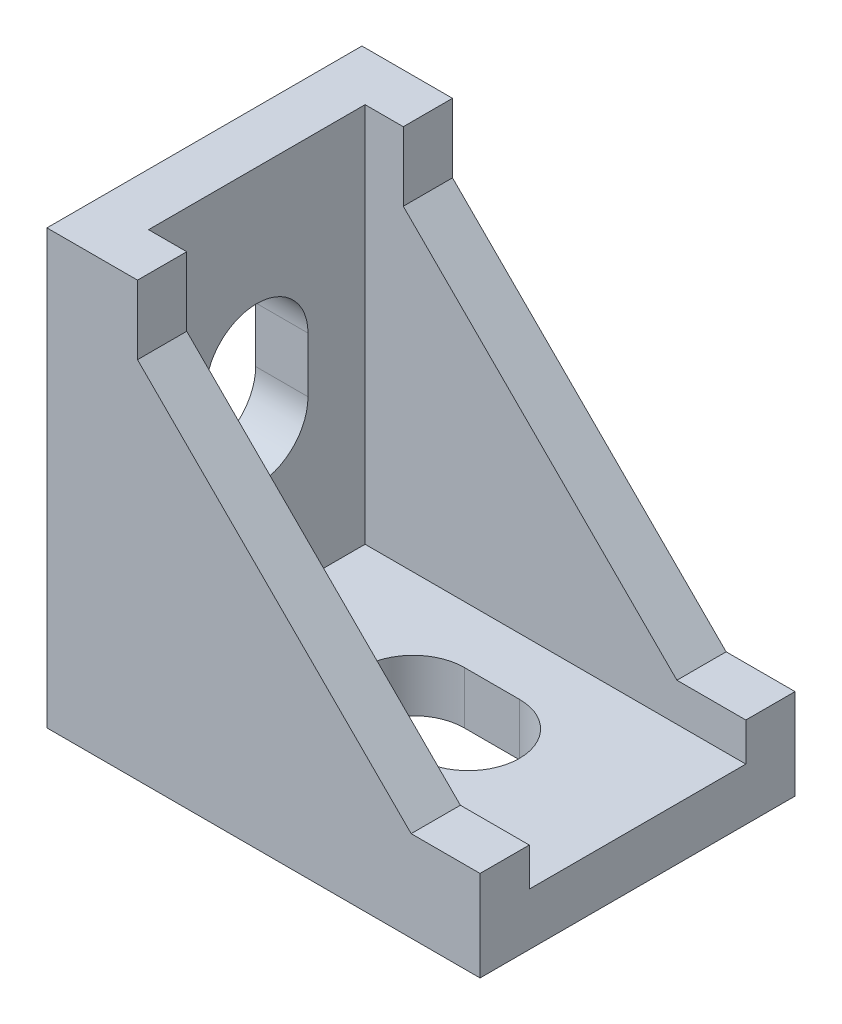
from build123d import *

# Parameters (mm, degrees)
BOSS_EXTRUDE1_DEPTH = 20.32
SKETCH2_W           = 24.5618
SKETCH2_H           = 13.97
CUT_EXTRUDE1_DEPTH  = 24.5618
CUT_EXTRUDE2_DEPTH  = 43.389008236
CIRPATTERN1_COUNT   = 2
CIRPATTERN1_ANGLE   = 270


with BuildPart() as part:
    # Sketch1 → Boss-Extrude1 (new body)
    with BuildSketch(Plane.XY):
        Polygon((0, 0), (0, 27.94), (5.842, 27.94), (5.842, 23.495), (23.495, 5.842), (27.94, 5.842), (27.94, 0), align=None)
    extrude(amount=-BOSS_EXTRUDE1_DEPTH)

    # Sketch2 → Cut-Extrude1 (cut)
    with BuildSketch(Plane(origin=(0, 27.94, 0), x_dir=(1, 0, 0), z_dir=(0, 1, 0))):
        with Locations((15.6591, 10.16)):
            Rectangle(SKETCH2_W, SKETCH2_H)
    extrude(amount=-CUT_EXTRUDE1_DEPTH, mode=Mode.SUBTRACT)

    # Sketch3 → Cut-Extrude2 (cut, through all)
    with BuildSketch(Plane(origin=(0, 3.3782, 0), x_dir=(1, 0, 0), z_dir=(0, 1, 0))):
        with BuildLine():
            Line((13.462, 13.462), (17.018, 13.462))
            ThreePointArc((17.018, 13.462), (20.32, 10.16), (17.018, 6.858))
            Line((17.018, 6.858), (13.462, 6.858))
            ThreePointArc((13.462, 6.858), (10.16, 10.16), (13.462, 13.462))
        make_face()
    cut_extrude2 = extrude(amount=-CUT_EXTRUDE2_DEPTH, mode=Mode.SUBTRACT)

    # CirPattern1: Cut-Extrude2 ×2 about axis
    cirpattern1_axis = Axis((0, 0, -20.32), (0, 0, -1))
    for i in range(1, CIRPATTERN1_COUNT):
        add(cut_extrude2.rotate(cirpattern1_axis, i * CIRPATTERN1_ANGLE / (CIRPATTERN1_COUNT - 1)), mode=Mode.SUBTRACT)


solid = part.part
